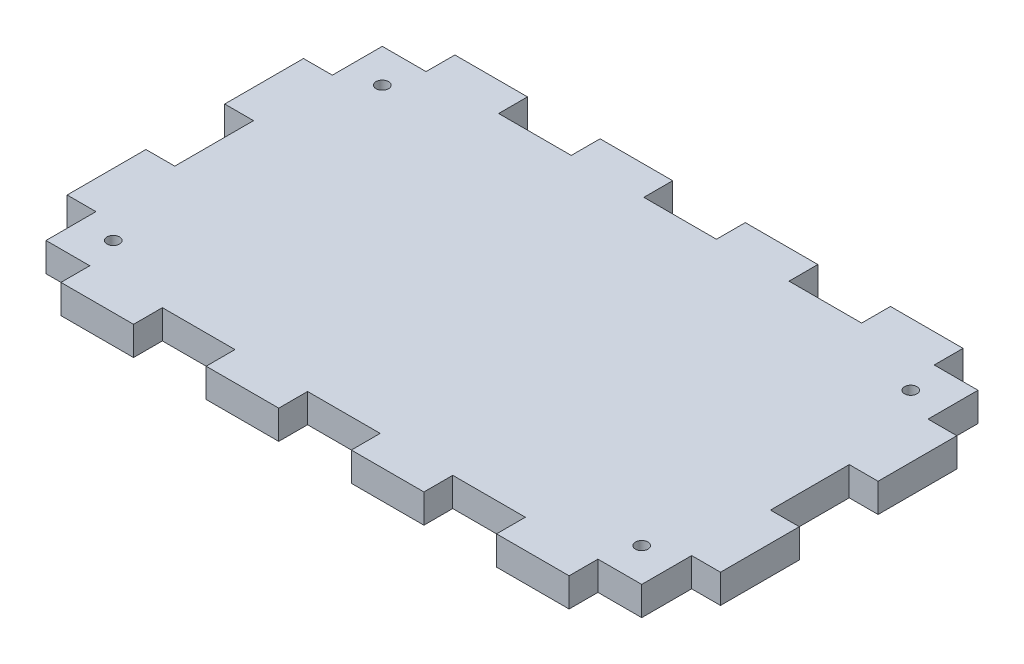
from build123d import *

# Parameters (mm, degrees)
AUFSATZ_LINEAR_AUSTRAGEN1_DEPTH = 3
SCHNITT_LINEAR_AUSTRAGEN1_REACH = 5
SKIZZE2_R                       = 0.65


with BuildPart() as part:
    # Skizze1 → Aufsatz-Linear austragen1 (new body)
    with BuildSketch(Plane(origin=(0, 0, 0), x_dir=(1, 0, 0), z_dir=(0, 1, 0))):
        Polygon((2.999994, 37.999416), (2.999994, 32.800036), (0, 32.800036), (0, 24.599138), (2.999994, 24.599138), (2.999994, 16.399764), (0, 16.399764), (0, 8.19912), (2.999994, 8.19912), (2.999994, 2.999994), (7.555738, 2.999994), (7.555738, 0), (15.11173, 0), (15.11173, 2.999994), (22.667468, 2.999994), (22.667468, 0), (30.223206, 0), (30.223206, 2.999994), (37.778944, 2.999994), (37.778944, 0), (45.333412, 0), (45.333412, 2.999994), (52.88915, 2.999994), (52.88915, 0), (60.444888, 0), (60.444888, 2.999994), (65.000632, 2.999994), (65.000632, 8.19912), (68.00088, 8.19912), (68.00088, 16.399764), (65.000632, 16.399764), (65.000632, 24.599138), (68.00088, 24.599138), (68.00088, 32.800036), (65.000632, 32.800036), (65.000632, 37.999416), (60.444888, 37.999416), (60.444888, 40.99941), (52.88915, 40.99941), (52.88915, 37.999416), (45.333412, 37.999416), (45.333412, 40.99941), (37.778944, 40.99941), (37.778944, 37.999416), (30.223206, 37.999416), (30.223206, 40.99941), (22.667468, 40.99941), (22.667468, 37.999416), (15.11173, 37.999416), (15.11173, 40.99941), (7.555738, 40.99941), (7.555738, 37.999416), align=None)
    extrude(amount=AUFSATZ_LINEAR_AUSTRAGEN1_DEPTH)

    # Skizze2 → Schnitt-Linear austragen1 (cut, up to next)
    with BuildSketch(Plane(origin=(0, 3, 0), x_dir=(1, 0, 0), z_dir=(0, 1, 0)), mode=Mode.PRIVATE) as schnitt_linear_austragen1_sk1:
        with Locations((6.501075, 34.499451)):
            Circle(SKIZZE2_R)
    schnitt_linear_austragen1_tool1 = extrude(schnitt_linear_austragen1_sk1.sketch, amount=-SCHNITT_LINEAR_AUSTRAGEN1_REACH, mode=Mode.PRIVATE) & part.part
    add(schnitt_linear_austragen1_tool1.solids().sort_by_distance((6.501075, 3, -34.499451))[0], mode=Mode.SUBTRACT)
    # Skizze2 → Schnitt-Linear austragen1 (cut, up to next)
    with BuildSketch(Plane(origin=(0, 3, 0), x_dir=(1, 0, 0), z_dir=(0, 1, 0)), mode=Mode.PRIVATE) as schnitt_linear_austragen1_sk2:
        with Locations((61.501075, 34.499451)):
            Circle(SKIZZE2_R)
    schnitt_linear_austragen1_tool2 = extrude(schnitt_linear_austragen1_sk2.sketch, amount=-SCHNITT_LINEAR_AUSTRAGEN1_REACH, mode=Mode.PRIVATE) & part.part
    add(schnitt_linear_austragen1_tool2.solids().sort_by_distance((61.501075, 3, -34.499451))[0], mode=Mode.SUBTRACT)
    # Skizze2 → Schnitt-Linear austragen1 (cut, up to next)
    with BuildSketch(Plane(origin=(0, 3, 0), x_dir=(1, 0, 0), z_dir=(0, 1, 0)), mode=Mode.PRIVATE) as schnitt_linear_austragen1_sk3:
        with Locations((61.501075, 6.499451)):
            Circle(SKIZZE2_R)
    schnitt_linear_austragen1_tool3 = extrude(schnitt_linear_austragen1_sk3.sketch, amount=-SCHNITT_LINEAR_AUSTRAGEN1_REACH, mode=Mode.PRIVATE) & part.part
    add(schnitt_linear_austragen1_tool3.solids().sort_by_distance((61.501075, 3, -6.499451))[0], mode=Mode.SUBTRACT)
    # Skizze2 → Schnitt-Linear austragen1 (cut, up to next)
    with BuildSketch(Plane(origin=(0, 3, 0), x_dir=(1, 0, 0), z_dir=(0, 1, 0)), mode=Mode.PRIVATE) as schnitt_linear_austragen1_sk4:
        with Locations((6.501075, 6.499451)):
            Circle(SKIZZE2_R)
    schnitt_linear_austragen1_tool4 = extrude(schnitt_linear_austragen1_sk4.sketch, amount=-SCHNITT_LINEAR_AUSTRAGEN1_REACH, mode=Mode.PRIVATE) & part.part
    add(schnitt_linear_austragen1_tool4.solids().sort_by_distance((6.501075, 3, -6.499451))[0], mode=Mode.SUBTRACT)


solid = part.part
